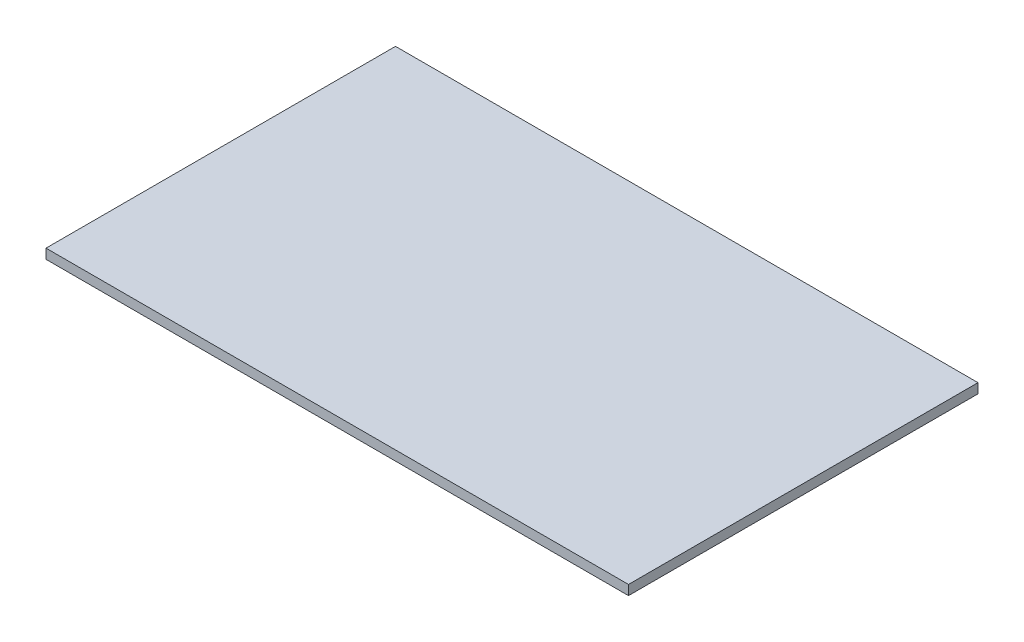
from build123d import *

# Parameters (mm, degrees)
SKETCH_1_W      = 600
SKETCH_1_H      = 360
EXTRUDE_1_DEPTH = 10


with BuildPart() as part:
    # Эскиз1 → Бобышка-Вытянуть1 (new body)
    with BuildSketch(Plane(origin=(0, 0, 0), x_dir=(1, 0, 0), z_dir=(0, 1, 0))):
        Rectangle(SKETCH_1_W, SKETCH_1_H)
    extrude(amount=EXTRUDE_1_DEPTH)


solid = part.part
